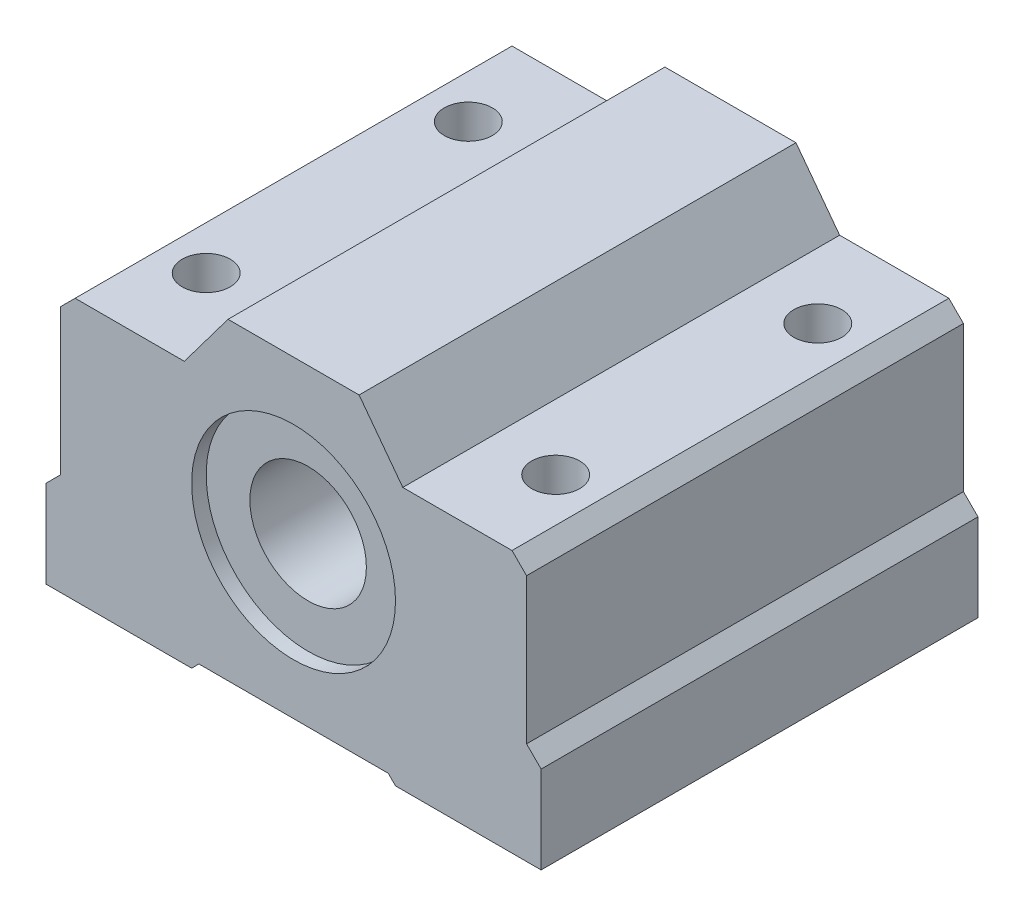
from build123d import *

# Parameters (mm, degrees)
BOSS_EXTRUDE1_DEPTH         = 30
SKETCH2_R                   = 4
CUT_EXTRUDE1_DEPTH          = 31
SKETCH3_R                   = 7
CUT_EXTRUDE2_DEPTH          = 1
SKETCH4_R                   = 7
CUT_EXTRUDE3_DEPTH          = 1
TAP_DRILL_FOR_M4X0_7_TAP1_D = 3.3


with BuildPart() as part:
    # Sketch1 → Boss-Extrude1 (new body)
    with BuildSketch(Plane.XY):
        Polygon((-17, -2.405243596), (-17, -8.405243596), (-7, -8.405243596), (-6.5, -7.905243596), (6.5, -7.905243596), (7, -8.405243596), (17, -8.405243596), (17, -2.405243596), (16, -1.405243596), (16, 8.594756404), (15, 9.594756404), (7.5, 9.594756404), (4.5, 13.594756404), (-4.5, 13.594756404), (-7.5, 9.594756404), (-15, 9.594756404), (-16, 8.594756404), (-16, -1.405243596), align=None)
    extrude(amount=BOSS_EXTRUDE1_DEPTH)

    # Sketch2 → Cut-Extrude1 (cut, through all)
    with BuildSketch(Plane(origin=(0, 0, 0), x_dir=(-1, 0, 0), z_dir=(0, 0, -1))):
        with Locations((0, 2.594756404)):
            Circle(SKETCH2_R)
    extrude(amount=-CUT_EXTRUDE1_DEPTH, mode=Mode.SUBTRACT)

    # Sketch3 → Cut-Extrude2 (cut)
    with BuildSketch(Plane(origin=(0, 0, 0), x_dir=(-1, 0, 0), z_dir=(0, 0, -1))):
        with Locations((0, 2.594756404)):
            Circle(SKETCH3_R)
    extrude(amount=-CUT_EXTRUDE2_DEPTH, mode=Mode.SUBTRACT)

    # Sketch4 → Cut-Extrude3 (cut)
    with BuildSketch(Plane.XY.offset(30)):
        with Locations((0, 2.594756404)):
            Circle(SKETCH4_R)
    extrude(amount=-CUT_EXTRUDE3_DEPTH, mode=Mode.SUBTRACT)

    # Tap Drill for M4x0.7 Tap1 (through all)
    with Locations(Plane(origin=(0, -8.405243596, 0), x_dir=(-1, 0, 0), z_dir=(0, -1, 0))):
        with Locations((-12, -6), (12, -6), (12, -24), (-12, -24)):
            Hole(TAP_DRILL_FOR_M4X0_7_TAP1_D / 2)


solid = part.part
